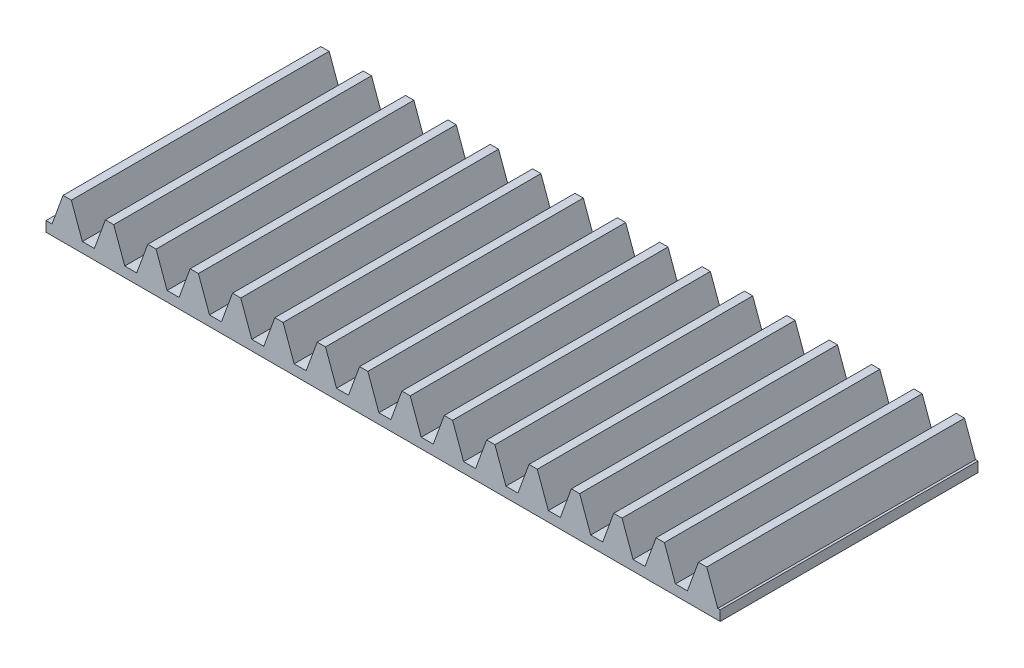
from build123d import *

# Parameters (mm, degrees)
BLANKSKE_W        = 50
BLANKSKE_H        = 3
BLANK_DEPTH       = 19.12
TOOTHCUTSIM_DEPTH = 54.615057586
TEETHCUTS_COUNT   = 17
TEETHCUTS_PITCH   = 3.14159265


with BuildPart() as part:
    # BlankSke → Blank (new body)
    with BuildSketch(Plane.XY):
        with Locations((25, 1.5)):
            Rectangle(BLANKSKE_W, BLANKSKE_H)
    extrude(amount=-BLANK_DEPTH)

    # TooCutSkeSim → ToothCutSim (cut, through all)
    with BuildSketch(Plane.XY):
        Polygon((0.44443537, 0.75), (-0.44443537, 0.75), (-1.272613241, 3.0254), (1.272613241, 3.0254), align=None)
    toothcutsim = extrude(amount=-TOOTHCUTSIM_DEPTH, mode=Mode.SUBTRACT)

    # TeethCuts: ToothCutSim ×17
    with Locations(*[(i * TEETHCUTS_PITCH, 0, 0) for i in range(1, TEETHCUTS_COUNT)]):
        add(toothcutsim, mode=Mode.SUBTRACT)


solid = part.part
